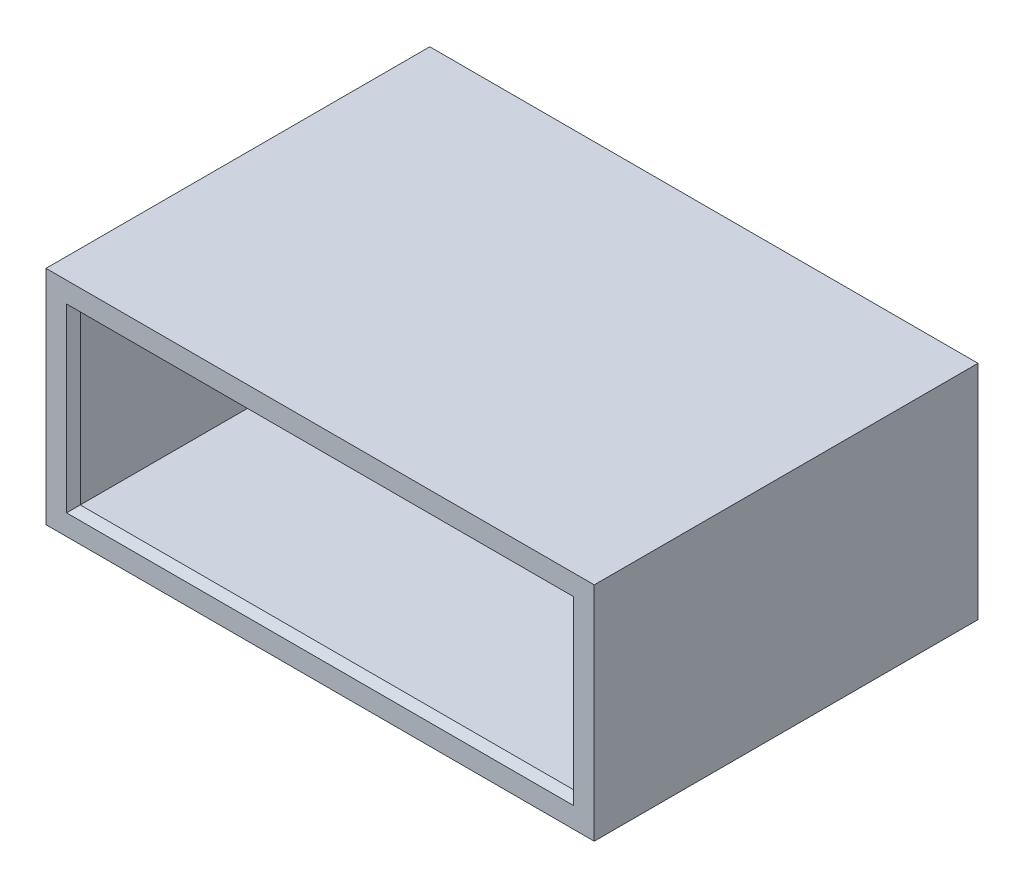
from build123d import *

# Parameters (mm, degrees)
SKETCH1_W           = 20
SKETCH1_H           = 8.1
SKETCH1_W_2         = 18
SKETCH1_H_2         = 6.1
BOSS_EXTRUDE1_DEPTH = 14
CHAMFER1_SIZE       = 0.25


with BuildPart() as part:
    # Sketch1 → Boss-Extrude1 (new body)
    with BuildSketch(Plane.XY):
        Rectangle(SKETCH1_W, SKETCH1_H)
        Rectangle(SKETCH1_W_2, SKETCH1_H_2, mode=Mode.SUBTRACT)
    extrude(amount=BOSS_EXTRUDE1_DEPTH)

    # Chamfer1
    chamfer1_edges = [part.edges().sort_by_distance(p)[0] for p in [
        (9, 0, 0),
        (0, 3.05, 0),
        (-9, 0, 0),
        (0, -3.05, 0),
        (9, 0, 14),
        (0, 3.05, 14),
        (-9, 0, 14),
        (0, -3.05, 14),
    ]]
    chamfer(chamfer1_edges, length=CHAMFER1_SIZE)


solid = part.part
